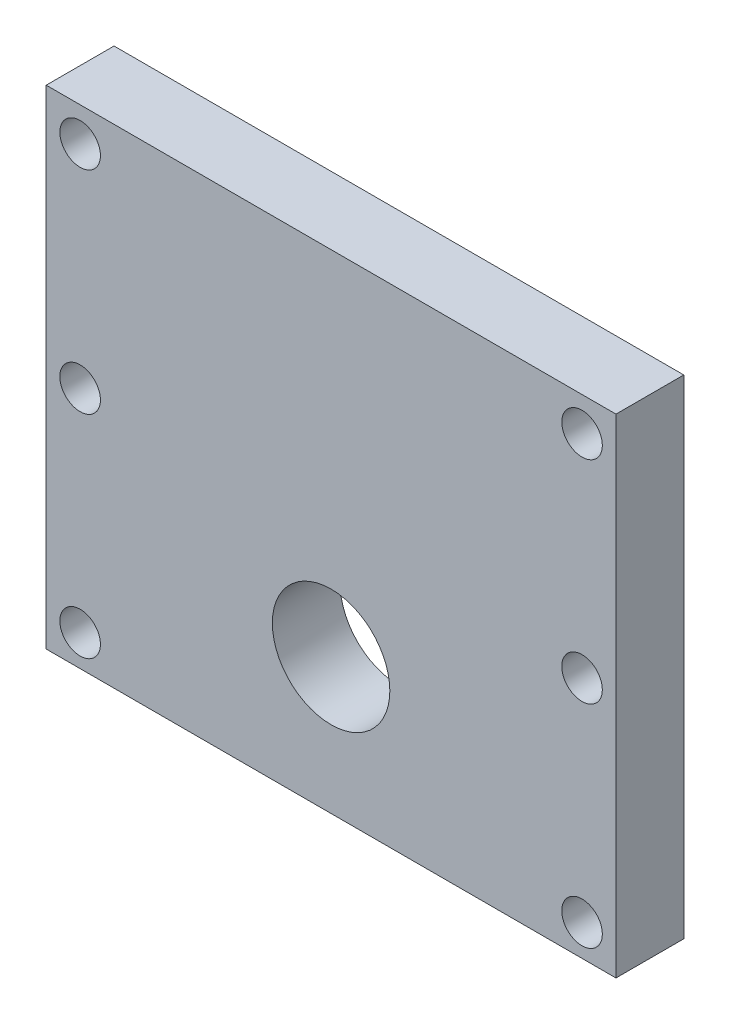
from build123d import *

# Parameters (mm, degrees)
SKETCH1_W                 = 53.34
SKETCH1_H                 = 45.72
BOSS_EXTRUDE1_DEPTH       = 6.35
SKETCH2_R                 = 5.5
CUT_EXTRUDE1_DEPTH        = 1
CUT_EXTRUDE1_DEPTH_BACK   = 7.35
F_6_CLEARANCE_HOLE1_D     = 3.7973
F_6_CLEARANCE_HOLE1_DEPTH = 6.35


with BuildPart() as part:
    # Sketch1 → Boss-Extrude1 (new body)
    with BuildSketch(Plane.XY):
        with Locations((26.67, 22.86)):
            Rectangle(SKETCH1_W, SKETCH1_H)
    extrude(amount=BOSS_EXTRUDE1_DEPTH)

    # Sketch2 → Cut-Extrude1 (cut, two sides)
    with BuildSketch(Plane.XY.offset(6.35)) as cut_extrude1_sk:
        with Locations((26.67, 12.7)):
            Circle(SKETCH2_R)
    extrude(amount=CUT_EXTRUDE1_DEPTH, mode=Mode.SUBTRACT)
    extrude(cut_extrude1_sk.sketch, amount=-CUT_EXTRUDE1_DEPTH_BACK, mode=Mode.SUBTRACT)

    # #6 Clearance Hole1
    with Locations(Plane.XY.offset(6.35)):
        with Locations((3.175, 42.545), (50.165, 42.545), (50.165, 22.733), (50.165, 2.921), (3.175, 22.733), (3.175, 2.921)):
            Hole(F_6_CLEARANCE_HOLE1_D / 2, depth=F_6_CLEARANCE_HOLE1_DEPTH)


solid = part.part
